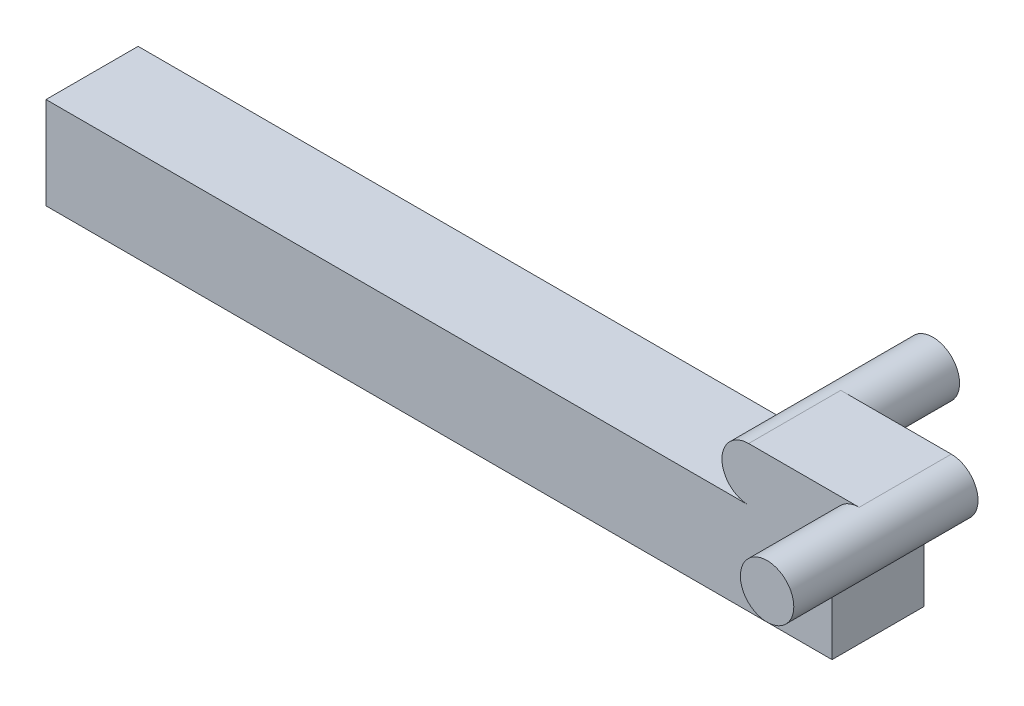
from build123d import *

# Parameters (mm, degrees)
EXTRUDE_1_DEPTH = 5
SKETCH_2_R      = 1.45
EXTRUDE_2_DEPTH = 5
SKETCH_3_R      = 1.45
EXTRUDE_3_DEPTH = 5
SKETCH_4_W      = 2.670391159
SKETCH_4_H      = 5
EXTRUDE_4_DEPTH = 5
SKETCH_5_W      = 5
SKETCH_5_H      = 5
EXTRUDE_5_DEPTH = 40


with BuildPart() as part:
    # 草图1 → 凸台-拉伸1 (new body)
    with BuildSketch(Plane.XY):
        with BuildLine():
            Line((0, 1.45), (6, 1.45))
            ThreePointArc((6, 1.45), (7.45, 0), (6, -1.45))
            Line((6, -1.45), (0, -1.45))
            ThreePointArc((0, -1.45), (-1.45, 0), (0, 1.45))
        make_face()
    extrude(amount=EXTRUDE_1_DEPTH)

    # 草图2 → 凸台-拉伸2 (add)
    with BuildSketch(Plane.XY.offset(5)):
        with Locations(Location((6, 0, 0), (0, 0, 90))):
            Circle(SKETCH_2_R)
    extrude(amount=EXTRUDE_2_DEPTH)

    # 草图3 → 凸台-拉伸3 (add)
    with BuildSketch(Plane(origin=(0, 0, 0), x_dir=(-1, 0, 0), z_dir=(0, 0, -1))):
        Circle(SKETCH_3_R)
    extrude(amount=EXTRUDE_3_DEPTH)

    # 草图4 → 凸台-拉伸4 (add)
    with BuildSketch(Plane.XZ.offset(1.45)):
        with Locations((3.190742226, 2.5)):
            Rectangle(SKETCH_4_W, SKETCH_4_H)
    extrude(amount=EXTRUDE_4_DEPTH)

    # 草图5 → 凸台-拉伸5 (add)
    with BuildSketch(Plane.ZY.offset(-1.855546646)):
        with Locations((2.5, -3.95)):
            Rectangle(SKETCH_5_W, SKETCH_5_H)
    extrude(amount=EXTRUDE_5_DEPTH)


solid = part.part
